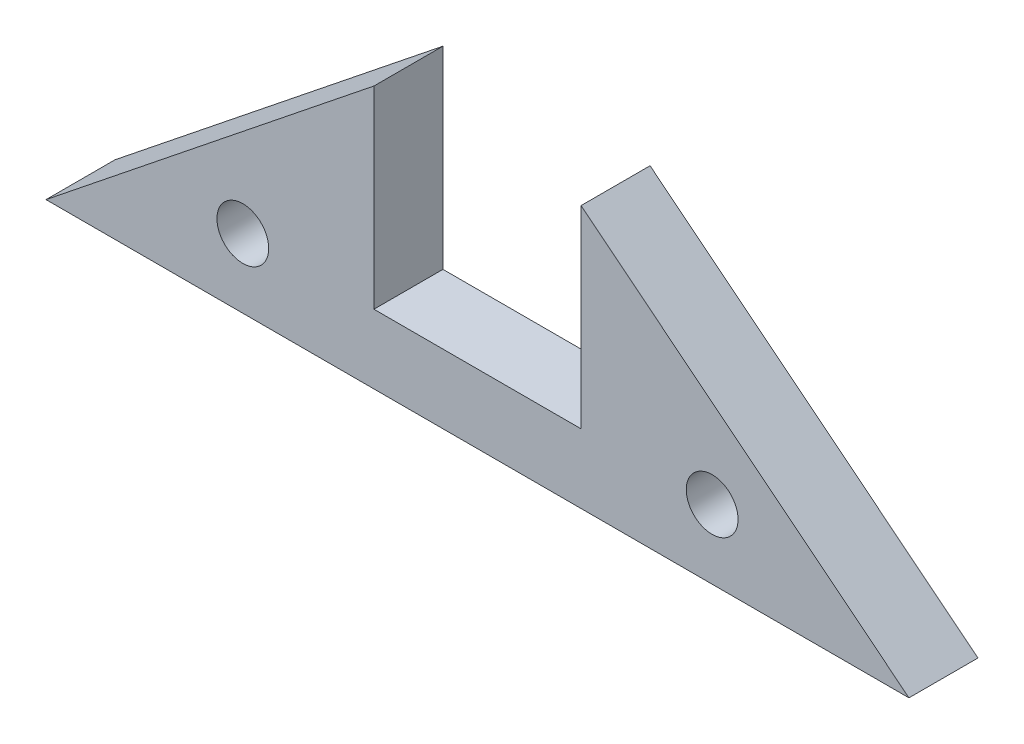
from build123d import *

# Parameters (mm, degrees)
BOSS_EXTRUDE1_DEPTH = 5.08
SKETCH2_R           = 1.905
CUT_EXTRUDE1_DEPTH  = 6.08
SKETCH5_W           = 15.24
SKETCH5_H           = 5.08
CUT_EXTRUDE2_DEPTH  = 21.32


with BuildPart() as part:
    # Sketch1 → Boss-Extrude1 (new body)
    with BuildSketch(Plane.XY):
        Polygon((0, 0), (63.5, 0), (31.75, 25.4), align=None)
    extrude(amount=BOSS_EXTRUDE1_DEPTH)

    # Sketch2 → Cut-Extrude1 (cut, through all)
    with BuildSketch(Plane.XY.offset(5.08)):
        with Locations((14.481967782, 5.08)):
            Circle(SKETCH2_R)
        with Locations((49.018032218, 5.08)):
            Circle(SKETCH2_R)
    extrude(amount=-CUT_EXTRUDE1_DEPTH, mode=Mode.SUBTRACT)

    # Sketch5 → Cut-Extrude2 (cut, through all)
    with BuildSketch(Plane(origin=(0, 5.08, 0), x_dir=(-1, 0, 0), z_dir=(0, -1, 0))):
        with Locations((-31.75, -2.54)):
            Rectangle(SKETCH5_W, SKETCH5_H)
    extrude(amount=-CUT_EXTRUDE2_DEPTH, mode=Mode.SUBTRACT)


solid = part.part
